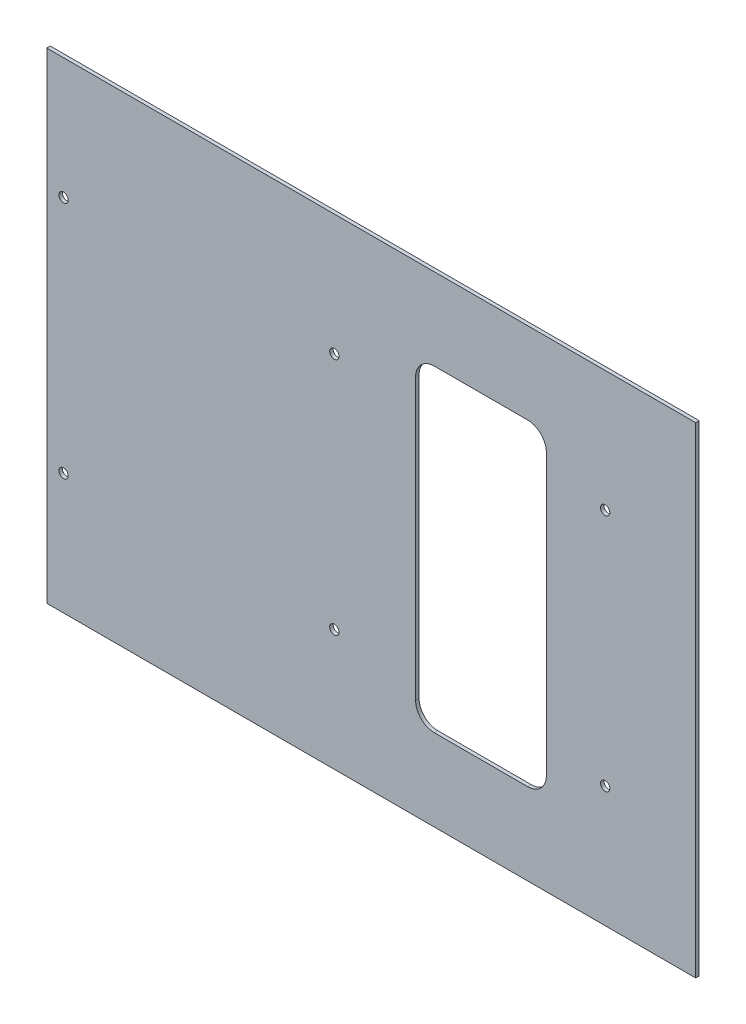
from build123d import *

# Parameters (mm, degrees)
SKETCH1_W          = 882.65
SKETCH1_H          = 654.05
EXTRUDE1_DEPTH     = 4.7625
SKETCH2_R          = 6.35
CUT_EXTRUDE1_DEPTH = 5.7625
SKETCH3_W          = 177.8
SKETCH3_H          = 431.8
CUT_EXTRUDE2_DEPTH = 5.7625
FILLET1_R          = 25.4


with BuildPart() as part:
    # Sketch1 → Extrude1 (new body)
    with BuildSketch(Plane.XY):
        with Locations((-835.025, 91.6)):
            Rectangle(SKETCH1_W, SKETCH1_H)
    extrude(amount=EXTRUDE1_DEPTH)

    # Sketch2 → Cut-Extrude1 (cut, through all)
    with BuildSketch(Plane(origin=(0, 0, 0), x_dir=(-1, 0, 0), z_dir=(0, 0, -1))):
        with Locations((516.89, 254)):
            Circle(SKETCH2_R)
        with Locations((516.89, -70.8)):
            Circle(SKETCH2_R)
        with Locations((885.19, 254)):
            Circle(SKETCH2_R)
        with Locations((885.19, -70.8)):
            Circle(SKETCH2_R)
        with Locations((1253.49, -70.8)):
            Circle(SKETCH2_R)
        with Locations((1253.49, 254)):
            Circle(SKETCH2_R)
    extrude(amount=-CUT_EXTRUDE1_DEPTH, mode=Mode.SUBTRACT)

    # Sketch3 → Cut-Extrude2 (cut, through all)
    with BuildSketch(Plane.XY.offset(4.7625)):
        with Locations((-685.8, 91.6)):
            Rectangle(SKETCH3_W, SKETCH3_H)
    extrude(amount=-CUT_EXTRUDE2_DEPTH, mode=Mode.SUBTRACT)

    # Fillet1
    fillet1_edges = [part.edges().sort_by_distance(p)[0] for p in [
        (-596.9, 307.5, 2.38125),
        (-596.9, -124.3, 2.38125),
        (-774.7, -124.3, 2.38125),
        (-774.7, 307.5, 2.38125),
    ]]
    fillet(fillet1_edges, radius=FILLET1_R)


solid = part.part
